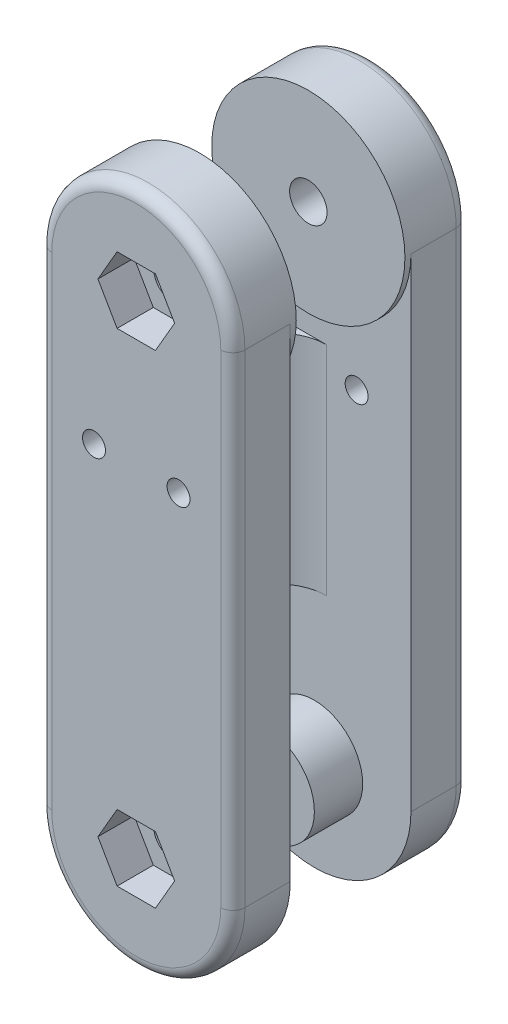
from build123d import *

# Parameters (mm, degrees)
SKETCH1_R           = 1.55
BOSS_EXTRUDE1_DEPTH = 4.75
FILLET2_R           = 1
CUT_EXTRUDE1_DEPTH  = 3
SKETCH3_W           = 5
SKETCH3_H           = 18
BOSS_EXTRUDE2_DEPTH = 5
SKETCH8_R           = 4
SKETCH8_R_2         = 1.55
BOSS_EXTRUDE4_DEPTH = 4
SKETCH9_R           = 8
SKETCH9_R_2         = 1.55
BOSS_EXTRUDE5_DEPTH = 0.5
FILLET3_R           = 4
SKETCH7_R           = 0.95
CUT_EXTRUDE3_DEPTH  = 20.5


with BuildPart() as part:
    # Sketch1 → Boss-Extrude1 (new body)
    with BuildSketch(Plane.XY):
        with BuildLine():
            Line((-8, 0), (-8, 40))
            ThreePointArc((-8, 40), (0, 48), (8, 40))
            Line((8, 40), (8, 0))
            ThreePointArc((8, 0), (0, -8), (-8, 0))
        make_face()
        with Locations((0, 40)):
            Circle(SKETCH1_R, mode=Mode.SUBTRACT)
        Circle(SKETCH1_R, mode=Mode.SUBTRACT)
    extrude(amount=BOSS_EXTRUDE1_DEPTH)

    # Fillet2
    fillet2_edges = [part.edges().sort_by_distance(p)[0] for p in [
        (0, 48, 4.75),
        (-8, 20, 4.75),
        (0, -8, 4.75),
        (8, 20, 4.75),
    ]]
    fillet(fillet2_edges, radius=FILLET2_R)

    # Sketch2 → Cut-Extrude1 (cut)
    with BuildSketch(Plane.XY.offset(4.75)):
        Polygon((3.175426481, 40), (1.58771324, 42.75), (-1.58771324, 42.75), (-3.175426481, 40), (-1.58771324, 37.25), (1.58771324, 37.25), align=None)
        Polygon((3.175426481, 0), (1.58771324, 2.75), (-1.58771324, 2.75), (-3.175426481, 0), (-1.58771324, -2.75), (1.58771324, -2.75), align=None)
    extrude(amount=-CUT_EXTRUDE1_DEPTH, mode=Mode.SUBTRACT)

    # Sketch3 → Boss-Extrude2 (add)
    with BuildSketch(Plane(origin=(0, 0, 0), x_dir=(-1, 0, 0), z_dir=(0, 0, -1))):
        with Locations((5.5, 21)):
            Rectangle(SKETCH3_W, SKETCH3_H)
    extrude(amount=BOSS_EXTRUDE2_DEPTH)

    # Sketch8 → Boss-Extrude4 (add)
    with BuildSketch(Plane(origin=(0, 0, 0), x_dir=(-1, 0, 0), z_dir=(0, 0, -1))):
        Circle(SKETCH8_R)
        Circle(SKETCH8_R_2, mode=Mode.SUBTRACT)
    extrude(amount=BOSS_EXTRUDE4_DEPTH)

    # Sketch9 → Boss-Extrude5 (add)
    with BuildSketch(Plane(origin=(0, 0, 0), x_dir=(-1, 0, 0), z_dir=(0, 0, -1))):
        with Locations((0, 40)):
            Circle(SKETCH9_R)
        with Locations((0, 40)):
            Circle(SKETCH9_R_2, mode=Mode.SUBTRACT)
    extrude(amount=BOSS_EXTRUDE5_DEPTH)

    # Fillet3
    fillet3_edges = [part.edges().sort_by_distance(p)[0] for p in [
        (-3, 21, 0),
    ]]
    fillet(fillet3_edges, radius=FILLET3_R)

    # Mirror5: part across plane


with BuildPart() as part_1:
    add(part.part)
    add(part.part.mirror(Plane.XY.offset(-5)))

    # Sketch7 → Cut-Extrude3 (cut, through all)
    with BuildSketch(Plane(origin=(0, 0, -14.75), x_dir=(-1, 0, 0), z_dir=(0, 0, -1))):
        with Locations((-3.5, 28)):
            Circle(SKETCH7_R)
        with Locations((3.5, 28)):
            Circle(SKETCH7_R)
    extrude(amount=-CUT_EXTRUDE3_DEPTH, mode=Mode.SUBTRACT)


solid = part_1.part
